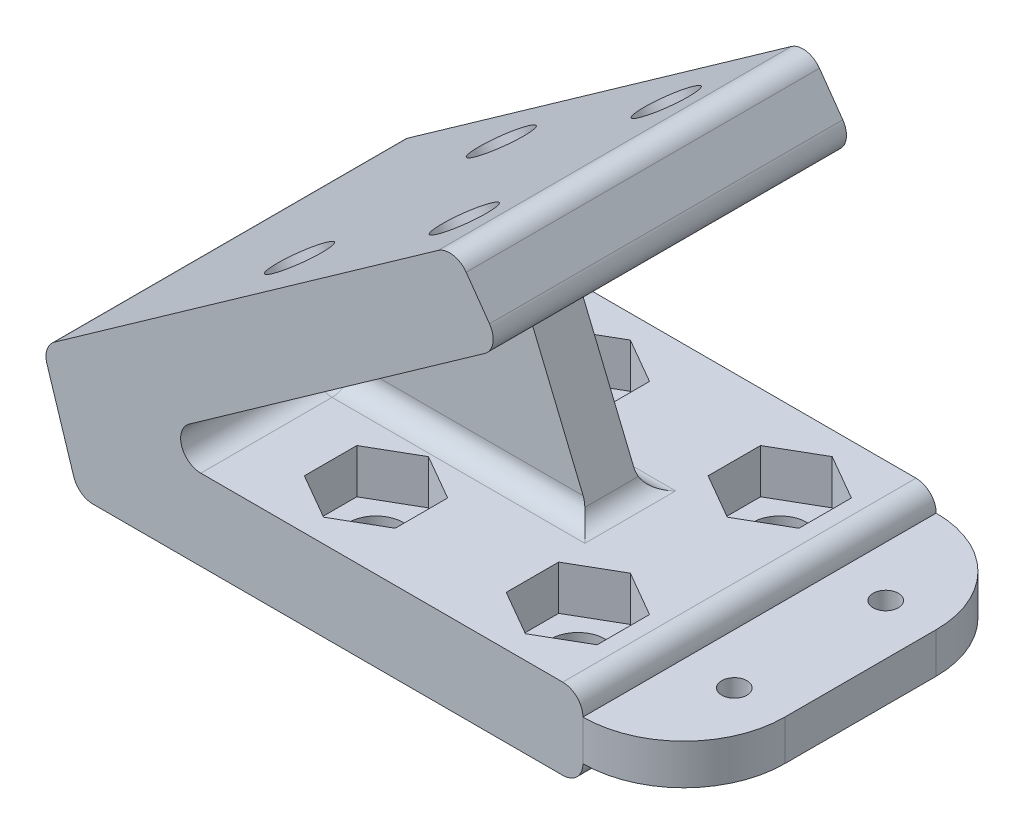
from build123d import *

# Parameters (mm, degrees)
BOSS_EXTRUDE1_DEPTH = 44.45
SKETCH2_R           = 3.429
CUT_EXTRUDE1_DEPTH  = 44.45
SKETCH3_R           = 3.429
CUT_EXTRUDE2_DEPTH  = 44.45
CUT_EXTRUDE3_DEPTH  = 5.588
CUT_EXTRUDE4_DEPTH  = 5.588
BOSS_EXTRUDE2_DEPTH = 3.175
FILLET1_R           = 2.54
SKETCH7_R           = 1.5875
BOSS_EXTRUDE3_DEPTH = 5.08


with BuildPart() as part:
    # Sketch1 → Boss-Extrude1 (new body)
    with BuildSketch(Plane.XY):
        Polygon((0, 0), (63.5, 0), (63.5, 10.16), (7.431912016, 10.16), (53.213794099, 42.527418233), (47.348550945, 50.823472882), (-4.50179061, 14.165703165), align=None)
    extrude(amount=BOSS_EXTRUDE1_DEPTH)

    # Sketch2 → Cut-Extrude1 (cut)
    with BuildSketch(Plane(origin=(0, 10.16, 0), x_dir=(1, 0, 0), z_dir=(0, 1, 0))):
        with Locations((53.34, -34.925)):
            Circle(SKETCH2_R)
        with Locations((53.34, -9.525)):
            Circle(SKETCH2_R)
        with Locations((27.94, -9.525)):
            Circle(SKETCH2_R)
        with Locations((27.94, -34.925)):
            Circle(SKETCH2_R)
    extrude(amount=-CUT_EXTRUDE1_DEPTH, mode=Mode.SUBTRACT)

    # Sketch3 → Cut-Extrude2 (cut)
    with BuildSketch(Plane(origin=(-2.312443215, 3.270820114, 0), x_dir=(0, 0, -1), z_dir=(0.577287712, -0.816540812, 0))):
        with Locations((-9.525, 32.44179061)):
            Circle(SKETCH3_R)
        with Locations((-9.525, 57.84179061)):
            Circle(SKETCH3_R)
        with Locations((-34.925, 57.84179061)):
            Circle(SKETCH3_R)
        with Locations((-34.925, 32.44179061)):
            Circle(SKETCH3_R)
    extrude(amount=-CUT_EXTRUDE2_DEPTH, mode=Mode.SUBTRACT)

    # Sketch4 → Cut-Extrude3 (cut)
    with BuildSketch(Plane(origin=(0, 10.16, 0), x_dir=(1, 0, 0), z_dir=(0, 1, 0))):
        Polygon((22.225, -31.625443212), (22.225, -38.224556788), (27.94, -41.524113577), (33.655, -38.224556788), (33.655, -31.625443212), (27.94, -28.325886423), align=None)
        Polygon((47.625, -31.625443212), (47.625, -38.224556788), (53.34, -41.524113577), (59.055, -38.224556788), (59.055, -31.625443212), (53.34, -28.325886423), align=None)
        Polygon((22.225, -6.225443212), (22.225, -12.824556788), (27.94, -16.124113577), (33.655, -12.824556788), (33.655, -6.225443212), (27.94, -2.925886423), align=None)
        Polygon((47.625, -6.225443212), (47.625, -12.824556788), (53.34, -16.124113577), (59.055, -12.824556788), (59.055, -6.225443212), (53.34, -2.925886423), align=None)
    extrude(amount=-CUT_EXTRUDE3_DEPTH, mode=Mode.SUBTRACT)

    # Sketch5 → Cut-Extrude4 (cut)
    with BuildSketch(Plane(origin=(-2.312443215, 3.270820114, 0), x_dir=(0, 0, -1), z_dir=(0.577287712, -0.816540812, 0))):
        Polygon((-2.925886423, 57.84179061), (-6.225443212, 63.55679061), (-12.824556788, 63.55679061), (-16.124113577, 57.84179061), (-12.824556788, 52.12679061), (-6.225443212, 52.12679061), align=None)
        Polygon((-28.325886423, 57.84179061), (-31.625443212, 63.55679061), (-38.224556788, 63.55679061), (-41.524113577, 57.84179061), (-38.224556788, 52.12679061), (-31.625443212, 52.12679061), align=None)
        Polygon((-2.925886423, 32.44179061), (-6.225443212, 38.15679061), (-12.824556788, 38.15679061), (-16.124113577, 32.44179061), (-12.824556788, 26.72679061), (-6.225443212, 26.72679061), align=None)
        Polygon((-28.325886423, 32.44179061), (-31.625443212, 38.15679061), (-38.224556788, 38.15679061), (-41.524113577, 32.44179061), (-38.224556788, 26.72679061), (-31.625443212, 26.72679061), align=None)
    extrude(amount=-CUT_EXTRUDE4_DEPTH, mode=Mode.SUBTRACT)

    # Sketch6 → Boss-Extrude2 (add, symmetric)
    with BuildSketch(Plane.XY.offset(22.225)):
        Polygon((7.431912016, 10.16), (34.372680379, 37.100768363), (45.531912016, 10.16), align=None)
    extrude(amount=BOSS_EXTRUDE2_DEPTH, both=True)

    # Fillet1
    fillet1_edges = [part.edges().sort_by_distance(p)[0] for p in [
        (-4.50179061, 14.165703165, 22.225),
        (47.348550945, 50.823472882, 22.225),
        (53.213794099, 42.527418233, 22.225),
        (7.431912016, 10.16, 34.925),
        (63.5, 10.16, 22.225),
        (63.5, 0, 22.225),
        (0, 0, 22.225),
        (7.431912016, 10.16, 9.525),
        (22.166849982, 20.577481285, 19.05),
        (36.901787948, 30.99496257, 22.225),
        (22.166849982, 20.577481285, 25.4),
        (45.531912016, 10.16, 22.225),
        (26.481912016, 10.16, 25.4),
        (26.481912016, 10.16, 19.05),
    ]]
    fillet(fillet1_edges, radius=FILLET1_R)

    # Sketch7 → Boss-Extrude3 (add)
    with BuildSketch(Plane(origin=(0, 2.54, 0), x_dir=(-1, 0, 0), z_dir=(0, -1, 0))):
        with BuildLine():
            Line((-63.5, 0), (-63.5, -44.45))
            ThreePointArc((-63.5, -44.45), (-72.480256121, -40.730256121), (-76.2, -31.75))
            Line((-76.2, -31.75), (-76.2, -12.7))
            ThreePointArc((-76.2, -12.7), (-72.480256121, -3.719743879), (-63.5, 0))
        make_face()
        with Locations((-69.85, -12.7)):
            Circle(SKETCH7_R, mode=Mode.SUBTRACT)
        with Locations((-69.85, -31.75)):
            Circle(SKETCH7_R, mode=Mode.SUBTRACT)
    extrude(amount=-BOSS_EXTRUDE3_DEPTH)


solid = part.part
